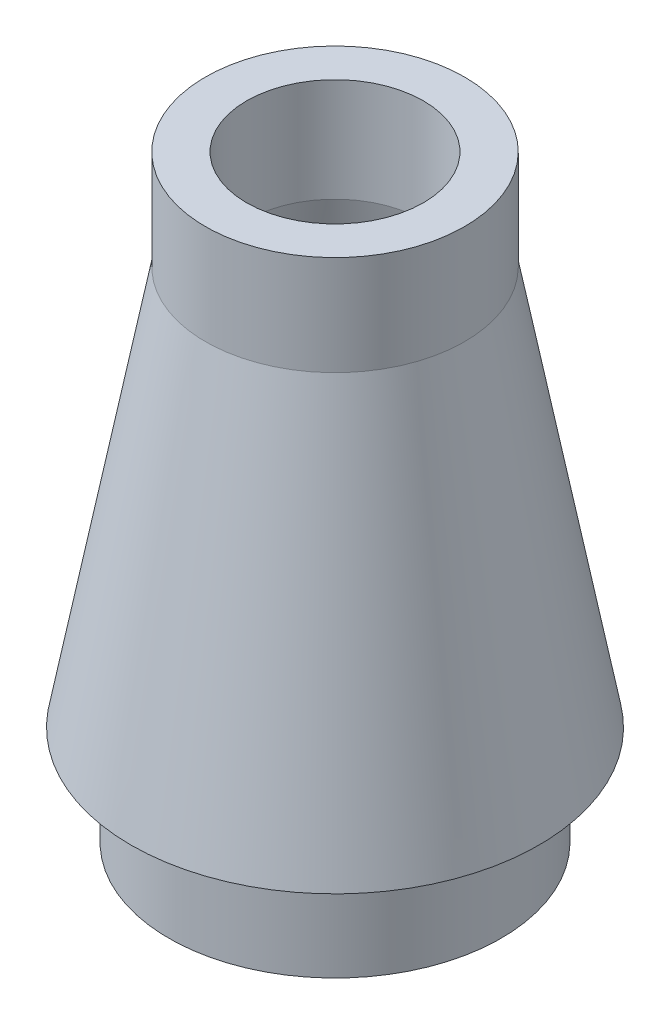
from build123d import *

# Parameters (mm, degrees)
SHELL1_T = -0.7874


with BuildPart() as part:
    # Sketch1 → Revolve1 (revolve)
    with BuildSketch(Plane.XY, mode=Mode.PRIVATE) as revolve1_sk:
        Polygon((0, 11.43), (-2.4765, 11.43), (-2.4765, 9.525), (-3.8989, 1.905), (-3.175, 1.905), (-3.175, 0), (0, 0), align=None)
    revolve(revolve1_sk.sketch.rotate(Axis((0, 0, 0), (0, 1, 0)), 270), axis=Axis((0, 0, 0), (0, 1, 0)))

    # Shell1
    shell1_openings = [part.faces().sort_by_distance(p)[0] for p in [
        (0, 0, 0),
        (0, 11.43, 0),
    ]]
    offset(amount=SHELL1_T, openings=shell1_openings, kind=Kind.INTERSECTION)


solid = part.part
